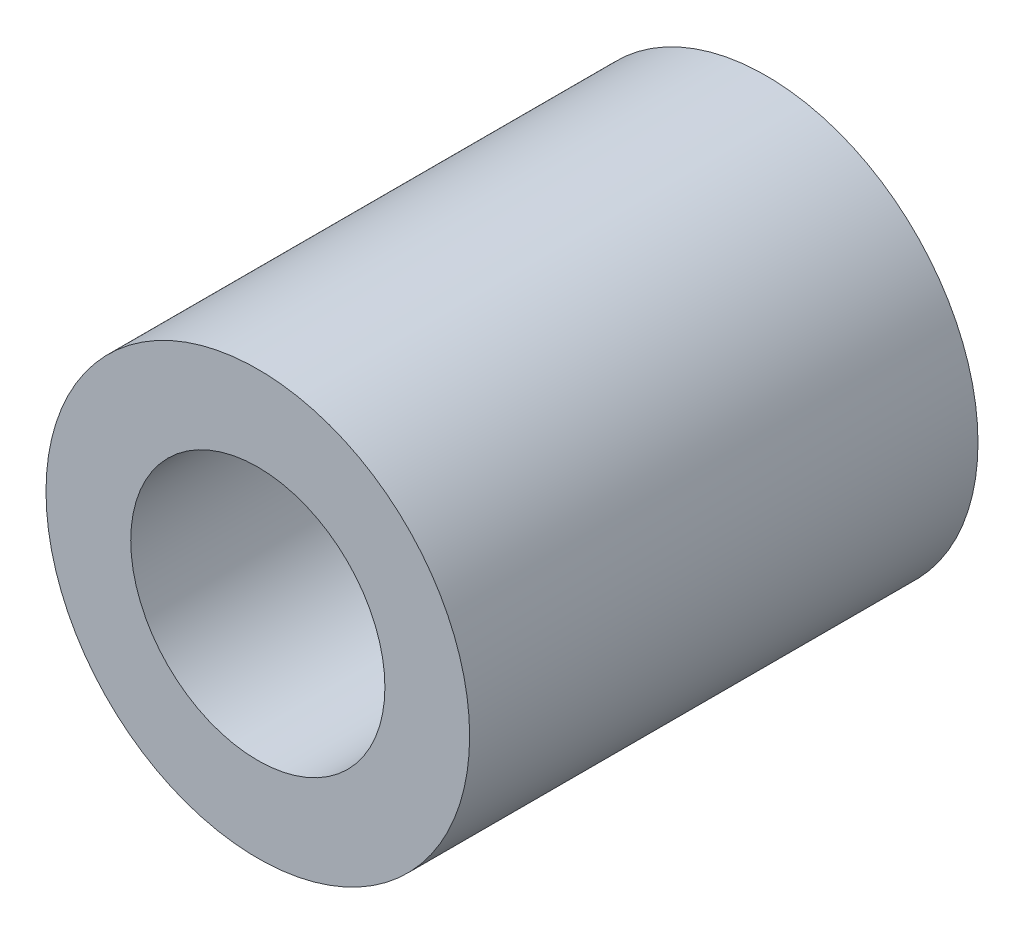
from build123d import *

# Parameters (mm, degrees)
SKETCH1_R           = 2.5
SKETCH1_R_2         = 1.5
BOSS_EXTRUDE1_DEPTH = 6


with BuildPart() as part:
    # Sketch1 → Boss-Extrude1 (new body)
    with BuildSketch(Plane.XY):
        Circle(SKETCH1_R)
        Circle(SKETCH1_R_2, mode=Mode.SUBTRACT)
    extrude(amount=BOSS_EXTRUDE1_DEPTH)


solid = part.part
